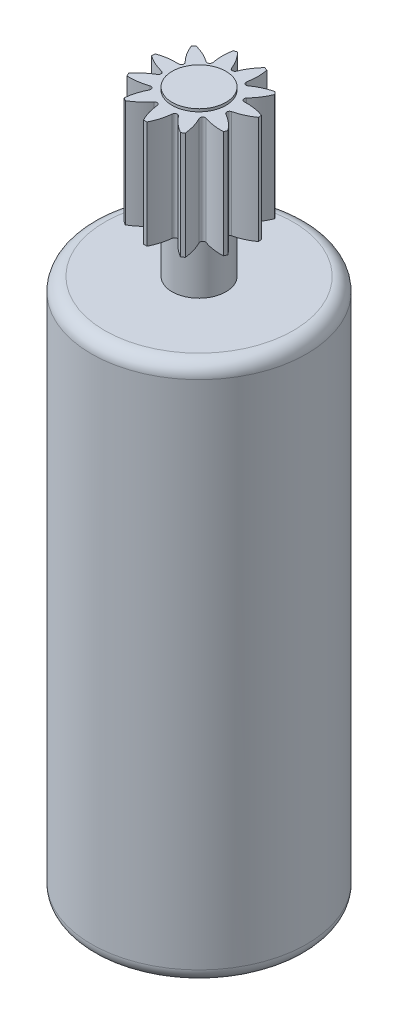
from build123d import *

# Parameters (mm, degrees)
FILLET1_R          = 0.5
CUT_EXTRUDE1_DEPTH = 4
CIRPATTERN1_COUNT  = 11


with BuildPart() as part:
    # Sketch1 → Revolve1 (revolve)
    with BuildSketch(Plane.XY):
        Polygon((0, 0), (0, 26.1), (1, 26.1), (1, 26), (2, 26), (2, 22), (1, 22), (1, 20), (4, 20), (4, 0), align=None)
    revolve(axis=Axis((0, 0, 0), (0, 1, 0)))

    # Fillet1
    fillet1_edges = [part.edges().sort_by_distance(p)[0] for p in [
        (-4, 20, 0),
        (-4, 0, 0),
    ]]
    fillet(fillet1_edges, radius=FILLET1_R)

    # Sketch2 → Cut-Extrude1 (cut)
    with BuildSketch(Plane(origin=(0, 26, 0), x_dir=(1, 0, 0), z_dir=(0, 1, 0))):
        with BuildLine():
            ThreePointArc((0.5, 1.936491673), (0, 2), (-0.5, 1.936491673))
            ThreePointArc((-0.5, 1.936491673), (-0.266119458, 1.637619869), (-0.092905413, 1.299949383))
            ThreePointArc((-0.092905413, 1.299949383), (0, 1.236943764), (0.092905413, 1.299949383))
            ThreePointArc((0.092905413, 1.299949383), (0.266119458, 1.637619869), (0.5, 1.936491673))
        make_face()
    cut_extrude1 = extrude(amount=-CUT_EXTRUDE1_DEPTH, mode=Mode.SUBTRACT)

    # CirPattern1: Cut-Extrude1 ×11 about axis
    cirpattern1_axis = Axis((0, 0, 0), (0, 1, 0))
    for i in range(1, CIRPATTERN1_COUNT):
        add(cut_extrude1.rotate(cirpattern1_axis, i * 360 / CIRPATTERN1_COUNT), mode=Mode.SUBTRACT)


solid = part.part
